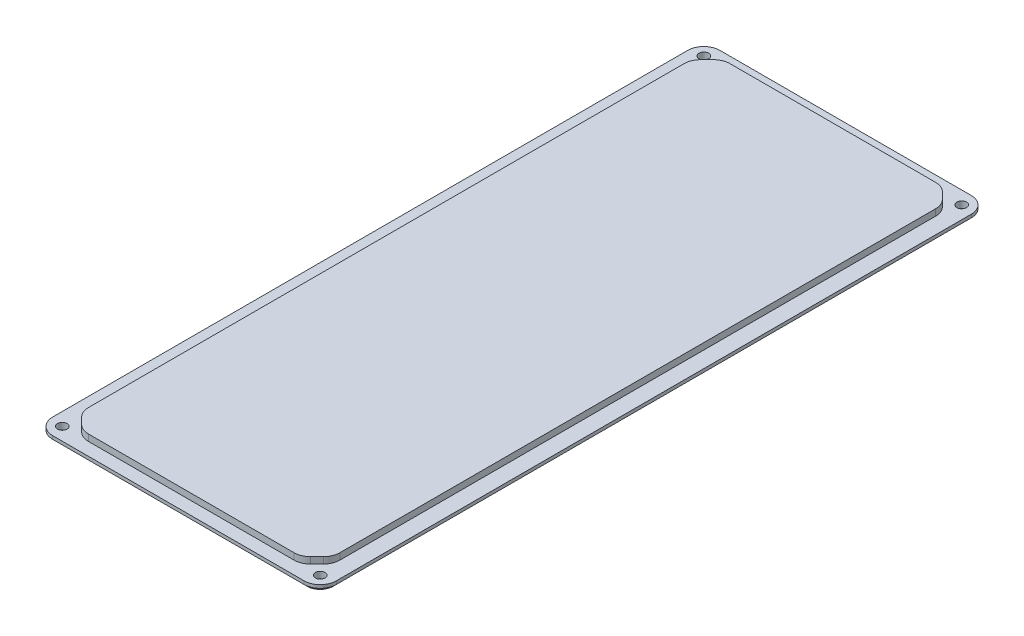
from build123d import *

# Parameters (mm, degrees)
SKETCH1_W                 = 88
SKETCH1_H                 = 207
BOSS_EXTRUDE1_DEPTH       = 2
SKETCH2_W                 = 78
SKETCH2_H                 = 199
BOSS_EXTRUDE2_DEPTH       = 2
CHAMFER1_SIZE             = 5
FILLET1_R                 = 5
F_3_0MM_DOWEL_HOLE1_D     = 3
F_3_0MM_DOWEL_HOLE1_DEPTH = 17.29
F_3_0MM_DOWEL_HOLE1_TIP   = 0.901290929
CHAMFER2_SIZE             = 1


with BuildPart() as part:
    # Sketch1 → Boss-Extrude1 (new body)
    with BuildSketch(Plane(origin=(0, 0, 0), x_dir=(1, 0, 0), z_dir=(0, 1, 0))):
        Rectangle(SKETCH1_W, SKETCH1_H)
    extrude(amount=BOSS_EXTRUDE1_DEPTH)

    # Sketch2 → Boss-Extrude2 (add)
    with BuildSketch(Plane(origin=(0, 2, 0), x_dir=(1, 0, 0), z_dir=(0, 1, 0))):
        Rectangle(SKETCH2_W, SKETCH2_H)
    extrude(amount=BOSS_EXTRUDE2_DEPTH)

    # Chamfer1
    chamfer1_edges = [part.edges().sort_by_distance(p)[0] for p in [
        (39, 3, 99.5),
        (39, 3, -99.5),
        (-39, 3, -99.5),
        (-39, 3, 99.5),
    ]]
    chamfer(chamfer1_edges, length=CHAMFER1_SIZE)

    # Fillet1
    fillet1_edges = [part.edges().sort_by_distance(p)[0] for p in [
        (-39, 3, 94.5),
        (-39, 3, -94.5),
        (34, 3, -99.5),
        (-34, 3, -99.5),
        (39, 3, 94.5),
        (39, 3, -94.5),
        (34, 3, 99.5),
        (-34, 3, 99.5),
        (44, 1, 103.5),
        (-44, 1, 103.5),
        (-44, 1, -103.5),
        (44, 1, -103.5),
    ]]
    fillet(fillet1_edges, radius=FILLET1_R)

    # Ø3.0mm Dowel Hole1
    with Locations(Plane(origin=(0, 0, 0), x_dir=(-1, 0, 0), z_dir=(0, -1, 0))):
        with Locations((-40, 99.5), (40, 99.5), (40, -99.5), (-40, -99.5)):
            Hole(F_3_0MM_DOWEL_HOLE1_D / 2, depth=F_3_0MM_DOWEL_HOLE1_DEPTH)
            with Locations((0, 0, -(F_3_0MM_DOWEL_HOLE1_DEPTH + F_3_0MM_DOWEL_HOLE1_TIP / 2))):  # 118° drill point
                Cone(0, F_3_0MM_DOWEL_HOLE1_D / 2, F_3_0MM_DOWEL_HOLE1_TIP, mode=Mode.SUBTRACT)

    # Chamfer2
    chamfer2_edges = [part.edges().sort_by_distance(p)[0] for p in [
        (0, 0, 103.5),
        (44, 0, 0),
        (-44, 0, 0),
        (0, 0, -103.5),
        (-42.535533906, 0, -102.035533906),
        (42.535533906, 0, -102.035533906),
        (42.535533906, 0, 102.035533906),
        (-42.535533906, 0, 102.035533906),
    ]]
    chamfer(chamfer2_edges, length=CHAMFER2_SIZE)


solid = part.part
